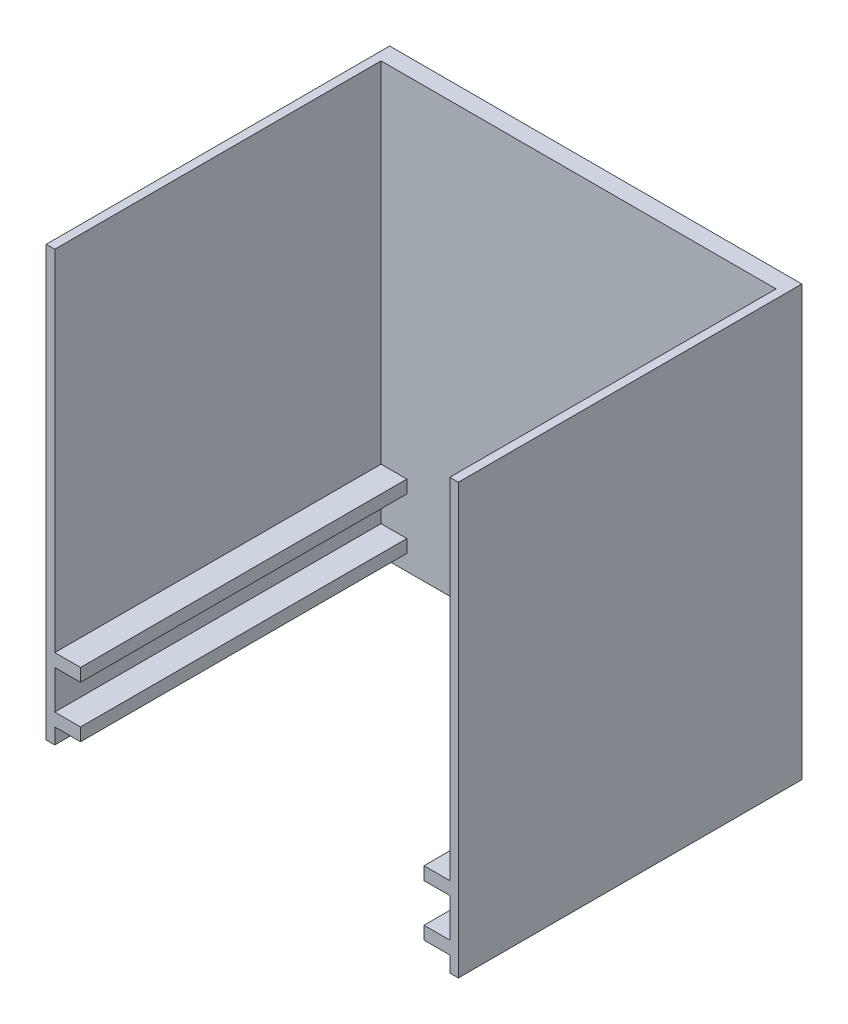
from build123d import *

# Parameters (mm, degrees)
SKETCH1_W           = 48
SKETCH1_H           = 50
BOSS_EXTRUDE1_DEPTH = 40
CUT_EXTRUDE5_START  = 40
CUT_EXTRUDE5_DEPTH  = 38


with BuildPart() as part:
    # Sketch1 → Boss-Extrude1 (new body)
    with BuildSketch(Plane.XY):
        with Locations((0, 2.677885393)):
            Rectangle(SKETCH1_W, SKETCH1_H)
    extrude(amount=BOSS_EXTRUDE1_DEPTH)

    # Sketch4 → Cut-Extrude5 (cut)
    with BuildSketch(Plane.XY.offset(CUT_EXTRUDE5_START)):
        Polygon((-23, -19), (-23, -14.5), (-20, -14.5), (-20, -13), (-23, -13), (-23, 27.677885393), (23, 27.677885393), (23, -13), (20, -13), (20, -14.5), (23, -14.5), (23, -19), (20, -19), (20, -20.5), (23, -20.5), (23, -22.322114607), (-23, -22.322114607), (-23, -20.5), (-20, -20.5), (-20, -19), align=None)
    extrude(amount=-CUT_EXTRUDE5_DEPTH, mode=Mode.SUBTRACT)


solid = part.part
